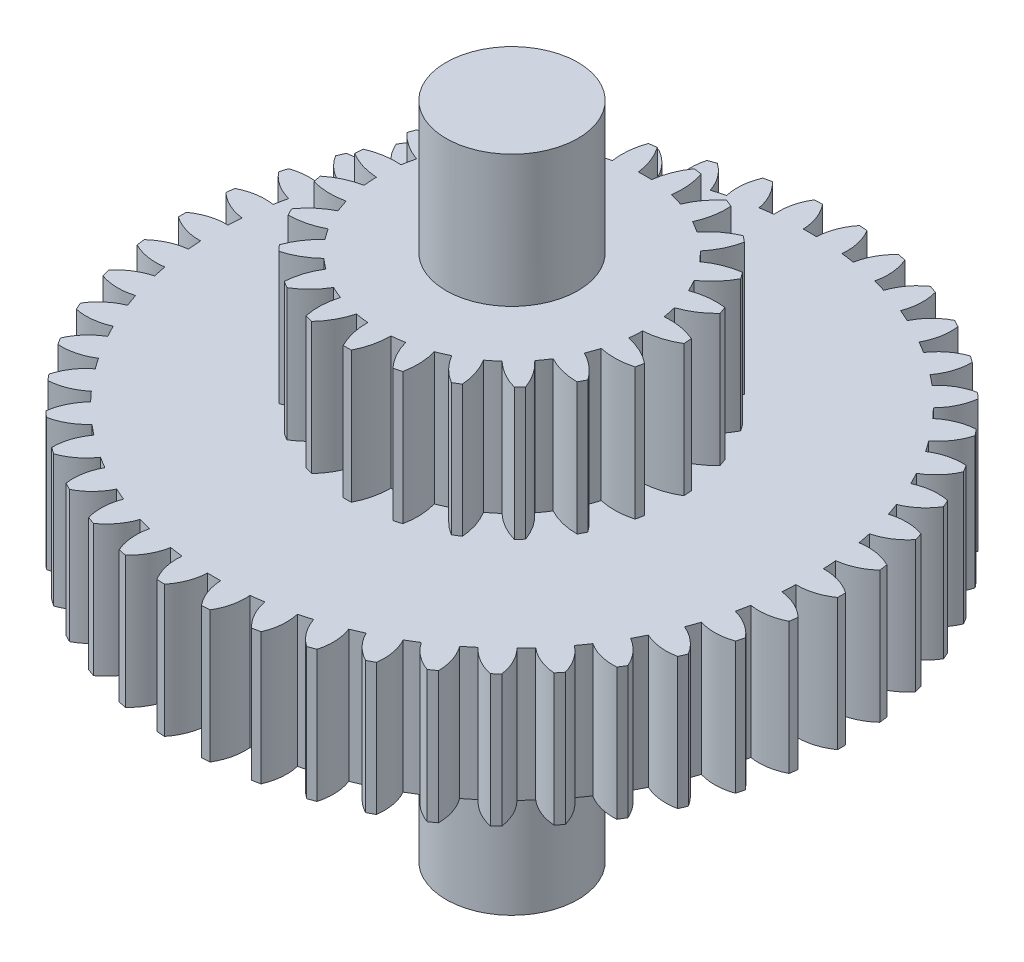
from build123d import *

# Parameters (mm, degrees)
BOSS_EXTRUDE1_DEPTH      = 1
SKETCH2_R                = 0.5
BOSS_EXTRUDE2_DEPTH      = 2
BOSS_EXTRUDE2_DEPTH_BACK = 3
BOSS_EXTRUDE3_DEPTH      = 1
SCALE1_SCALE             = 2
CUT_EXTRUDE1_DEPTH       = 2.5


with BuildPart() as part:
    # Sketch1 → Boss-Extrude1 (new body)
    with BuildSketch(Plane(origin=(0, 0, 0), x_dir=(1, 0, 0), z_dir=(0, 1, 0))):
        with BuildLine():
            ThreePointArc((-1.122849348, 2.23365381), (-1.150162594, 2.219713046), (-1.17730279, 2.20543831))
            ThreePointArc((-1.17730279, 2.20543831), (-1.174225974, 2.07727607), (-1.131251341, 1.956494417))
            ThreePointArc((-1.131251341, 1.956494417), (-1.174259727, 1.930987854), (-1.216693282, 1.904536022))
            ThreePointArc((-1.216693282, 1.904536022), (-1.3041624, 1.998259979), (-1.416540223, 2.059954804))
            ThreePointArc((-1.416540223, 2.059954804), (-1.441700805, 2.042424733), (-1.466644473, 2.024587363))
            ThreePointArc((-1.466644473, 2.024587363), (-1.446144892, 1.898037792), (-1.387124094, 1.784232818))
            ThreePointArc((-1.387124094, 1.784232818), (-1.426258754, 1.753107517), (-1.464695223, 1.721124023))
            ThreePointArc((-1.464695223, 1.721124023), (-1.564111726, 1.802064654), (-1.683843634, 1.847882739))
            ThreePointArc((-1.683843634, 1.847882739), (-1.706382858, 1.827089911), (-1.728665344, 1.806022184))
            ThreePointArc((-1.728665344, 1.806022184), (-1.691124866, 1.683442662), (-1.617157349, 1.578734337))
            ThreePointArc((-1.617157349, 1.578734337), (-1.651689279, 1.542570104), (-1.685412664, 1.505650741))
            ThreePointArc((-1.685412664, 1.505650741), (-1.79492461, 1.572300274), (-1.919780224, 1.601388114))
            ThreePointArc((-1.919780224, 1.601388114), (-1.939278227, 1.577719861), (-1.958484451, 1.553814228))
            ThreePointArc((-1.958484451, 1.553814228), (-1.904602384, 1.43748818), (-1.817066023, 1.343827023))
            ThreePointArc((-1.817066023, 1.343827023), (-1.846351958, 1.303297528), (-1.874734055, 1.262130034))
            ThreePointArc((-1.874734055, 1.262130034), (-1.992301445, 1.313246914), (-2.119954941, 1.325062658))
            ThreePointArc((-2.119954941, 1.325062658), (-2.136048511, 1.298959875), (-2.151820698, 1.272661654))
            ThreePointArc((-2.151820698, 1.272661654), (-2.082600763, 1.164756013), (-1.983126195, 1.083886754))
            ThreePointArc((-1.983126195, 1.083886754), (-2.006620594, 1.039746985), (-2.029132698, 0.995098232))
            ThreePointArc((-2.029132698, 0.995098232), (-2.152565474, 1.02973025), (-2.280638908, 1.024053793))
            ThreePointArc((-2.280638908, 1.024053793), (-2.293028254, 0.996002725), (-2.305072596, 0.967801801))
            ThreePointArc((-2.305072596, 0.967801801), (-2.22180423, 0.870326645), (-2.112244478, 0.803755726))
            ThreePointArc((-2.112244478, 0.803755726), (-2.129509684, 0.756827924), (-2.145732439, 0.709529634))
            ThreePointArc((-2.145732439, 0.709529634), (-2.272731281, 0.727031659), (-2.398838888, 0.703968742))
            ThreePointArc((-2.398838888, 0.703968742), (-2.407293218, 0.674491928), (-2.415385354, 0.644913631))
            ThreePointArc((-2.415385354, 0.644913631), (-2.319619689, 0.559684739), (-2.202015642, 0.508652249))
            ThreePointArc((-2.202015642, 0.508652249), (-2.212730038, 0.459810589), (-2.222361244, 0.41074384))
            ThreePointArc((-2.222361244, 0.41074384), (-2.350560404, 0.410789844), (-2.472353038, 0.370770087))
            ThreePointArc((-2.472353038, 0.370770087), (-2.476714865, 0.340416623), (-2.480704053, 0.310011941))
            ThreePointArc((-2.480704053, 0.310011941), (-2.374225021, 0.238616965), (-2.250767422, 0.204073543))
            ThreePointArc((-2.250767422, 0.204073543), (-2.254731418, 0.154227854), (-2.257591664, 0.104306666))
            ThreePointArc((-2.257591664, 0.104306666), (-2.384603034, 0.086895792), (-2.499811928, 0.030664685))
            ThreePointArc((-2.499811928, 0.030664685), (-2.5, 0), (-2.499811928, -0.030664685))
            ThreePointArc((-2.499811928, -0.030664685), (-2.384603034, -0.086895792), (-2.257591664, -0.104306666))
            ThreePointArc((-2.257591664, -0.104306666), (-2.254731418, -0.154227854), (-2.250767422, -0.204073543))
            ThreePointArc((-2.250767422, -0.204073543), (-2.374225021, -0.238616965), (-2.480704053, -0.310011941))
            ThreePointArc((-2.480704053, -0.310011941), (-2.476714865, -0.340416623), (-2.472353038, -0.370770087))
            ThreePointArc((-2.472353038, -0.370770087), (-2.350560404, -0.410789844), (-2.222361244, -0.41074384))
            ThreePointArc((-2.222361244, -0.41074384), (-2.212730038, -0.459810589), (-2.202015642, -0.508652249))
            ThreePointArc((-2.202015642, -0.508652249), (-2.319619689, -0.559684739), (-2.415385354, -0.644913631))
            ThreePointArc((-2.415385354, -0.644913631), (-2.407293218, -0.674491928), (-2.398838888, -0.703968742))
            ThreePointArc((-2.398838888, -0.703968742), (-2.272731281, -0.727031659), (-2.145732439, -0.709529634))
            ThreePointArc((-2.145732439, -0.709529634), (-2.129509684, -0.756827924), (-2.112244478, -0.803755726))
            ThreePointArc((-2.112244478, -0.803755726), (-2.22180423, -0.870326645), (-2.305072596, -0.967801801))
            ThreePointArc((-2.305072596, -0.967801801), (-2.293028254, -0.996002725), (-2.280638908, -1.024053793))
            ThreePointArc((-2.280638908, -1.024053793), (-2.152565474, -1.02973025), (-2.029132698, -0.995098232))
            ThreePointArc((-2.029132698, -0.995098232), (-2.006620594, -1.039746985), (-1.983126195, -1.083886754))
            ThreePointArc((-1.983126195, -1.083886754), (-2.082600763, -1.164756013), (-2.151820698, -1.272661654))
            ThreePointArc((-2.151820698, -1.272661654), (-2.136048511, -1.298959875), (-2.119954941, -1.325062658))
            ThreePointArc((-2.119954941, -1.325062658), (-1.992301445, -1.313246914), (-1.874734055, -1.262130034))
            ThreePointArc((-1.874734055, -1.262130034), (-1.846351958, -1.303297528), (-1.817066023, -1.343827023))
            ThreePointArc((-1.817066023, -1.343827023), (-1.904602384, -1.43748818), (-1.958484451, -1.553814228))
            ThreePointArc((-1.958484451, -1.553814228), (-1.939278227, -1.577719861), (-1.919780224, -1.601388114))
            ThreePointArc((-1.919780224, -1.601388114), (-1.79492461, -1.572300274), (-1.685412664, -1.505650741))
            ThreePointArc((-1.685412664, -1.505650741), (-1.651689279, -1.542570104), (-1.617157349, -1.578734337))
            ThreePointArc((-1.617157349, -1.578734337), (-1.691124866, -1.683442662), (-1.728665344, -1.806022184))
            ThreePointArc((-1.728665344, -1.806022184), (-1.706382858, -1.827089911), (-1.683843634, -1.847882739))
            ThreePointArc((-1.683843634, -1.847882739), (-1.564111726, -1.802064654), (-1.464695223, -1.721124023))
            ThreePointArc((-1.464695223, -1.721124023), (-1.426258754, -1.753107517), (-1.387124094, -1.784232818))
            ThreePointArc((-1.387124094, -1.784232818), (-1.446144892, -1.898037792), (-1.466644473, -2.024587363))
            ThreePointArc((-1.466644473, -2.024587363), (-1.441700805, -2.042424733), (-1.416540223, -2.059954804))
            ThreePointArc((-1.416540223, -2.059954804), (-1.3041624, -1.998259979), (-1.216693282, -1.904536022))
            ThreePointArc((-1.216693282, -1.904536022), (-1.174259727, -1.930987854), (-1.131251341, -1.956494417))
            ThreePointArc((-1.131251341, -1.956494417), (-1.174225974, -2.07727607), (-1.17730279, -2.20543831))
            ThreePointArc((-1.17730279, -2.20543831), (-1.150162594, -2.219713046), (-1.122849348, -2.23365381))
            ThreePointArc((-1.122849348, -2.23365381), (-1.019918995, -2.157231501), (-0.946026647, -2.052470118))
            ThreePointArc((-0.946026647, -2.052470118), (-0.900386463, -2.072897541), (-0.854305516, -2.092310227))
            ThreePointArc((-0.854305516, -2.092310227), (-0.880433448, -2.217818624), (-0.866030184, -2.345206115))
            ThreePointArc((-0.866030184, -2.345206115), (-0.83719903, -2.355652305), (-0.808241914, -2.365744071))
            ThreePointArc((-0.808241914, -2.365744071), (-0.71667643, -2.276017883), (-0.657737325, -2.162170579))
            ThreePointArc((-0.657737325, -2.162170579), (-0.609740703, -2.176193069), (-0.561445596, -2.189150256))
            ThreePointArc((-0.561445596, -2.189150256), (-0.570240113, -2.317047414), (-0.538625074, -2.441287167))
            ThreePointArc((-0.538625074, -2.441287167), (-0.508640033, -2.447710219), (-0.478578463, -2.453764996))
            ThreePointArc((-0.478578463, -2.453764996), (-0.400083539, -2.352406357), (-0.357195602, -2.231593893))
            ThreePointArc((-0.357195602, -2.231593893), (-0.307736627, -2.238950238), (-0.258127007, -2.245210558))
            ThreePointArc((-0.258127007, -2.245210558), (-0.249424284, -2.373113995), (-0.201186398, -2.491891658))
            ThreePointArc((-0.201186398, -2.491891658), (-0.170606033, -2.494171923), (-0.14, -2.496076922))
            ThreePointArc((-0.14, -2.496076922), (-0.076037848, -2.384973952), (-0.05, -2.259446835))
            ThreePointArc((-0.05, -2.259446835), (0, -2.26), (0.05, -2.259446835))
            ThreePointArc((0.05, -2.259446835), (0.076037848, -2.384973952), (0.14, -2.496076922))
            ThreePointArc((0.14, -2.496076922), (0.170606033, -2.494171923), (0.201186398, -2.491891658))
            ThreePointArc((0.201186398, -2.491891658), (0.249424284, -2.373113995), (0.258127007, -2.245210558))
            ThreePointArc((0.258127007, -2.245210558), (0.307736627, -2.238950238), (0.357195602, -2.231593893))
            ThreePointArc((0.357195602, -2.231593893), (0.400083539, -2.352406357), (0.478578463, -2.453764996))
            ThreePointArc((0.478578463, -2.453764996), (0.508640033, -2.447710219), (0.538625074, -2.441287167))
            ThreePointArc((0.538625074, -2.441287167), (0.570240113, -2.317047414), (0.561445596, -2.189150256))
            ThreePointArc((0.561445596, -2.189150256), (0.609740703, -2.176193069), (0.657737325, -2.162170579))
            ThreePointArc((0.657737325, -2.162170579), (0.71667643, -2.276017883), (0.808241914, -2.365744071))
            ThreePointArc((0.808241914, -2.365744071), (0.83719903, -2.355652305), (0.866030184, -2.345206115))
            ThreePointArc((0.866030184, -2.345206115), (0.880433448, -2.217818624), (0.854305516, -2.092310227))
            ThreePointArc((0.854305516, -2.092310227), (0.900386463, -2.072897541), (0.946026647, -2.052470118))
            ThreePointArc((0.946026647, -2.052470118), (1.019918995, -2.157231501), (1.122849348, -2.23365381))
            ThreePointArc((1.122849348, -2.23365381), (1.150162594, -2.219713046), (1.17730279, -2.20543831))
            ThreePointArc((1.17730279, -2.20543831), (1.174225974, -2.07727607), (1.131251341, -1.956494417))
            ThreePointArc((1.131251341, -1.956494417), (1.174259727, -1.930987854), (1.216693282, -1.904536022))
            ThreePointArc((1.216693282, -1.904536022), (1.3041624, -1.998259979), (1.416540223, -2.059954804))
            ThreePointArc((1.416540223, -2.059954804), (1.441700805, -2.042424733), (1.466644473, -2.024587363))
            ThreePointArc((1.466644473, -2.024587363), (1.446144892, -1.898037792), (1.387124094, -1.784232818))
            ThreePointArc((1.387124094, -1.784232818), (1.426258754, -1.753107517), (1.464695223, -1.721124023))
            ThreePointArc((1.464695223, -1.721124023), (1.564111726, -1.802064654), (1.683843634, -1.847882739))
            ThreePointArc((1.683843634, -1.847882739), (1.706382858, -1.827089911), (1.728665344, -1.806022184))
            ThreePointArc((1.728665344, -1.806022184), (1.691124866, -1.683442662), (1.617157349, -1.578734337))
            ThreePointArc((1.617157349, -1.578734337), (1.651689279, -1.542570104), (1.685412664, -1.505650741))
            ThreePointArc((1.685412664, -1.505650741), (1.79492461, -1.572300274), (1.919780224, -1.601388114))
            ThreePointArc((1.919780224, -1.601388114), (1.939278227, -1.577719861), (1.958484451, -1.553814228))
            ThreePointArc((1.958484451, -1.553814228), (1.904602384, -1.43748818), (1.817066023, -1.343827023))
            ThreePointArc((1.817066023, -1.343827023), (1.846351958, -1.303297528), (1.874734055, -1.262130034))
            ThreePointArc((1.874734055, -1.262130034), (1.992301445, -1.313246914), (2.119954941, -1.325062658))
            ThreePointArc((2.119954941, -1.325062658), (2.136048511, -1.298959875), (2.151820698, -1.272661654))
            ThreePointArc((2.151820698, -1.272661654), (2.082600763, -1.164756013), (1.983126195, -1.083886754))
            ThreePointArc((1.983126195, -1.083886754), (2.006620594, -1.039746985), (2.029132698, -0.995098232))
            ThreePointArc((2.029132698, -0.995098232), (2.152565474, -1.02973025), (2.280638908, -1.024053793))
            ThreePointArc((2.280638908, -1.024053793), (2.293028254, -0.996002725), (2.305072596, -0.967801801))
            ThreePointArc((2.305072596, -0.967801801), (2.22180423, -0.870326645), (2.112244478, -0.803755726))
            ThreePointArc((2.112244478, -0.803755726), (2.129509684, -0.756827924), (2.145732439, -0.709529634))
            ThreePointArc((2.145732439, -0.709529634), (2.272731281, -0.727031659), (2.398838888, -0.703968742))
            ThreePointArc((2.398838888, -0.703968742), (2.407293218, -0.674491928), (2.415385354, -0.644913631))
            ThreePointArc((2.415385354, -0.644913631), (2.319619689, -0.559684739), (2.202015642, -0.508652249))
            ThreePointArc((2.202015642, -0.508652249), (2.212730038, -0.459810589), (2.222361244, -0.41074384))
            ThreePointArc((2.222361244, -0.41074384), (2.350560404, -0.410789844), (2.472353038, -0.370770087))
            ThreePointArc((2.472353038, -0.370770087), (2.476714865, -0.340416623), (2.480704053, -0.310011941))
            ThreePointArc((2.480704053, -0.310011941), (2.374225021, -0.238616965), (2.250767422, -0.204073543))
            ThreePointArc((2.250767422, -0.204073543), (2.254731418, -0.154227854), (2.257591664, -0.104306666))
            ThreePointArc((2.257591664, -0.104306666), (2.384603034, -0.086895792), (2.499811928, -0.030664685))
            ThreePointArc((2.499811928, -0.030664685), (2.5, 0), (2.499811928, 0.030664685))
            ThreePointArc((2.499811928, 0.030664685), (2.384603034, 0.086895792), (2.257591664, 0.104306666))
            ThreePointArc((2.257591664, 0.104306666), (2.254731418, 0.154227854), (2.250767422, 0.204073543))
            ThreePointArc((2.250767422, 0.204073543), (2.374225021, 0.238616965), (2.480704053, 0.310011941))
            ThreePointArc((2.480704053, 0.310011941), (2.476714865, 0.340416623), (2.472353038, 0.370770087))
            ThreePointArc((2.472353038, 0.370770087), (2.350560404, 0.410789844), (2.222361244, 0.41074384))
            ThreePointArc((2.222361244, 0.41074384), (2.212730038, 0.459810589), (2.202015642, 0.508652249))
            ThreePointArc((2.202015642, 0.508652249), (2.319619689, 0.559684739), (2.415385354, 0.644913631))
            ThreePointArc((2.415385354, 0.644913631), (2.407293218, 0.674491928), (2.398838888, 0.703968742))
            ThreePointArc((2.398838888, 0.703968742), (2.272731281, 0.727031659), (2.145732439, 0.709529634))
            ThreePointArc((2.145732439, 0.709529634), (2.129509684, 0.756827924), (2.112244478, 0.803755726))
            ThreePointArc((2.112244478, 0.803755726), (2.22180423, 0.870326645), (2.305072596, 0.967801801))
            ThreePointArc((2.305072596, 0.967801801), (2.293028254, 0.996002725), (2.280638908, 1.024053793))
            ThreePointArc((2.280638908, 1.024053793), (2.152565474, 1.02973025), (2.029132698, 0.995098232))
            ThreePointArc((2.029132698, 0.995098232), (2.006620594, 1.039746985), (1.983126195, 1.083886754))
            ThreePointArc((1.983126195, 1.083886754), (2.082600763, 1.164756013), (2.151820698, 1.272661654))
            ThreePointArc((2.151820698, 1.272661654), (2.136048511, 1.298959875), (2.119954941, 1.325062658))
            ThreePointArc((2.119954941, 1.325062658), (1.992301445, 1.313246914), (1.874734055, 1.262130034))
            ThreePointArc((1.874734055, 1.262130034), (1.846351958, 1.303297528), (1.817066023, 1.343827023))
            ThreePointArc((1.817066023, 1.343827023), (1.904602384, 1.43748818), (1.958484451, 1.553814228))
            ThreePointArc((1.958484451, 1.553814228), (1.939278227, 1.577719861), (1.919780224, 1.601388114))
            ThreePointArc((1.919780224, 1.601388114), (1.79492461, 1.572300274), (1.685412664, 1.505650741))
            ThreePointArc((1.685412664, 1.505650741), (1.651689279, 1.542570104), (1.617157349, 1.578734337))
            ThreePointArc((1.617157349, 1.578734337), (1.691124866, 1.683442662), (1.728665344, 1.806022184))
            ThreePointArc((1.728665344, 1.806022184), (1.706382858, 1.827089911), (1.683843634, 1.847882739))
            ThreePointArc((1.683843634, 1.847882739), (1.564111726, 1.802064654), (1.464695223, 1.721124023))
            ThreePointArc((1.464695223, 1.721124023), (1.426258754, 1.753107517), (1.387124094, 1.784232818))
            ThreePointArc((1.387124094, 1.784232818), (1.446144892, 1.898037792), (1.466644473, 2.024587363))
            ThreePointArc((1.466644473, 2.024587363), (1.441700805, 2.042424733), (1.416540223, 2.059954804))
            ThreePointArc((1.416540223, 2.059954804), (1.3041624, 1.998259979), (1.216693282, 1.904536022))
            ThreePointArc((1.216693282, 1.904536022), (1.174259727, 1.930987854), (1.131251341, 1.956494417))
            ThreePointArc((1.131251341, 1.956494417), (1.174225974, 2.07727607), (1.17730279, 2.20543831))
            ThreePointArc((1.17730279, 2.20543831), (1.150162594, 2.219713046), (1.122849348, 2.23365381))
            ThreePointArc((1.122849348, 2.23365381), (1.019918995, 2.157231501), (0.946026647, 2.052470118))
            ThreePointArc((0.946026647, 2.052470118), (0.900386463, 2.072897541), (0.854305516, 2.092310227))
            ThreePointArc((0.854305516, 2.092310227), (0.880433448, 2.217818624), (0.866030184, 2.345206115))
            ThreePointArc((0.866030184, 2.345206115), (0.83719903, 2.355652305), (0.808241914, 2.365744071))
            ThreePointArc((0.808241914, 2.365744071), (0.71667643, 2.276017883), (0.657737325, 2.162170579))
            ThreePointArc((0.657737325, 2.162170579), (0.609740703, 2.176193069), (0.561445596, 2.189150256))
            ThreePointArc((0.561445596, 2.189150256), (0.570240113, 2.317047414), (0.538625074, 2.441287167))
            ThreePointArc((0.538625074, 2.441287167), (0.508640033, 2.447710219), (0.478578463, 2.453764996))
            ThreePointArc((0.478578463, 2.453764996), (0.400083539, 2.352406357), (0.357195602, 2.231593893))
            ThreePointArc((0.357195602, 2.231593893), (0.307736627, 2.238950238), (0.258127007, 2.245210558))
            ThreePointArc((0.258127007, 2.245210558), (0.249424284, 2.373113995), (0.201186398, 2.491891658))
            ThreePointArc((0.201186398, 2.491891658), (0.170606033, 2.494171923), (0.14, 2.496076922))
            ThreePointArc((0.14, 2.496076922), (0.076037848, 2.384973952), (0.05, 2.259446835))
            ThreePointArc((0.05, 2.259446835), (0, 2.26), (-0.05, 2.259446835))
            ThreePointArc((-0.05, 2.259446835), (-0.076037848, 2.384973952), (-0.14, 2.496076922))
            ThreePointArc((-0.14, 2.496076922), (-0.170606033, 2.494171923), (-0.201186398, 2.491891658))
            ThreePointArc((-0.201186398, 2.491891658), (-0.249424284, 2.373113995), (-0.258127007, 2.245210558))
            ThreePointArc((-0.258127007, 2.245210558), (-0.307736627, 2.238950238), (-0.357195602, 2.231593893))
            ThreePointArc((-0.357195602, 2.231593893), (-0.400083539, 2.352406357), (-0.478578463, 2.453764996))
            ThreePointArc((-0.478578463, 2.453764996), (-0.508640033, 2.447710219), (-0.538625074, 2.441287167))
            ThreePointArc((-0.538625074, 2.441287167), (-0.570240113, 2.317047414), (-0.561445596, 2.189150256))
            ThreePointArc((-0.561445596, 2.189150256), (-0.609740703, 2.176193069), (-0.657737325, 2.162170579))
            ThreePointArc((-0.657737325, 2.162170579), (-0.71667643, 2.276017883), (-0.808241914, 2.365744071))
            ThreePointArc((-0.808241914, 2.365744071), (-0.83719903, 2.355652305), (-0.866030184, 2.345206115))
            ThreePointArc((-0.866030184, 2.345206115), (-0.880433448, 2.217818624), (-0.854305516, 2.092310227))
            ThreePointArc((-0.854305516, 2.092310227), (-0.900386463, 2.072897541), (-0.946026647, 2.052470118))
            ThreePointArc((-0.946026647, 2.052470118), (-1.019918995, 2.157231501), (-1.122849348, 2.23365381))
        make_face()
    extrude(amount=BOSS_EXTRUDE1_DEPTH)

    # Sketch2 → Boss-Extrude2 (add, two sides)
    with BuildSketch(Plane.XZ) as boss_extrude2_sk:
        Circle(SKETCH2_R)
    extrude(amount=BOSS_EXTRUDE2_DEPTH)
    extrude(boss_extrude2_sk.sketch, amount=-BOSS_EXTRUDE2_DEPTH_BACK)

    # Sketch3 → Boss-Extrude3 (add)
    with BuildSketch(Plane(origin=(0, 1, 0), x_dir=(1, 0, 0), z_dir=(0, 1, 0))):
        with BuildLine():
            ThreePointArc((-0.765012261, 0.988562715), (-0.78885993, 0.969639113), (-0.812239679, 0.95014036))
            ThreePointArc((-0.812239679, 0.95014036), (-0.771519926, 0.830895064), (-0.703111612, 0.725075211))
            ThreePointArc((-0.703111612, 0.725075211), (-0.738144324, 0.689378675), (-0.771366926, 0.651991614))
            ThreePointArc((-0.771366926, 0.651991614), (-0.881608438, 0.71301905), (-1.003354559, 0.74550629))
            ThreePointArc((-1.003354559, 0.74550629), (-1.021212366, 0.720850403), (-1.03846443, 0.695766935))
            ThreePointArc((-1.03846443, 0.695766935), (-0.96708268, 0.591929637), (-0.872661277, 0.508490212))
            ThreePointArc((-0.872661277, 0.508490212), (-0.896764071, 0.464665688), (-0.918667781, 0.41970169))
            ThreePointArc((-0.918667781, 0.41970169), (-1.041286243, 0.44872326), (-1.16728264, 0.447159074))
            ThreePointArc((-1.16728264, 0.447159074), (-1.177826153, 0.418599515), (-1.187671024, 0.38979166))
            ThreePointArc((-1.187671024, 0.38979166), (-1.090921335, 0.309063496), (-0.977489647, 0.254192821))
            ThreePointArc((-0.977489647, 0.254192821), (-0.988874929, 0.205490573), (-0.997835248, 0.156284412))
            ThreePointArc((-0.997835248, 0.156284412), (-1.123736611, 0.151147718), (-1.244638708, 0.115648115))
            ThreePointArc((-1.244638708, 0.115648115), (-1.247085961, 0.085303017), (-1.248793492, 0.05490732))
            ThreePointArc((-1.248793492, 0.05490732), (-1.133851346, 0.003275529), (-1.009822082, -0.018956889))
            ThreePointArc((-1.009822082, -0.018956889), (-1.007645457, -0.068924837), (-1.00299784, -0.118723766))
            ThreePointArc((-1.00299784, -0.118723766), (-1.122844575, -0.157637759), (-1.229685616, -0.224439935))
            ThreePointArc((-1.229685616, -0.224439935), (-1.22385511, -0.254320016), (-1.21729866, -0.284049244))
            ThreePointArc((-1.21729866, -0.284049244), (-1.092688789, -0.302755369), (-0.967260632, -0.290700653))
            ThreePointArc((-0.967260632, -0.290700653), (-0.951683531, -0.338228408), (-0.933772671, -0.384926745))
            ThreePointArc((-0.933772671, -0.384926745), (-1.038676294, -0.454731964), (-1.123532368, -0.547882303))
            ThreePointArc((-1.123532368, -0.547882303), (-1.109856523, -0.575081297), (-1.095522354, -0.601939176))
            ThreePointArc((-1.095522354, -0.601939176), (-0.970486504, -0.586332286), (-0.852961886, -0.54088448))
            ThreePointArc((-0.852961886, -0.54088448), (-0.825139592, -0.582447125), (-0.795293854, -0.622581469))
            ThreePointArc((-0.795293854, -0.622581469), (-0.877474144, -0.71810078), (-0.934051864, -0.830690746))
            ThreePointArc((-0.934051864, -0.830690746), (-0.913544955, -0.853191429), (-0.892496167, -0.875186032))
            ThreePointArc((-0.892496167, -0.875186032), (-0.776307675, -0.826423619), (-0.67540286, -0.750953379))
            ThreePointArc((-0.67540286, -0.750953379), (-0.637398824, -0.783468404), (-0.597831731, -0.814062173))
            ThreePointArc((-0.597831731, -0.814062173), (-0.651193751, -0.928211346), (-0.675297006, -1.051890657))
            ThreePointArc((-0.675297006, -1.051890657), (-0.649479938, -1.068024256), (-0.623277623, -1.083524344))
            ThreePointArc((-0.623277623, -1.083524344), (-0.524553656, -1.005222894), (-0.447752293, -0.905327501))
            ThreePointArc((-0.447752293, -0.905327501), (-0.402385101, -0.926383415), (-0.356031163, -0.94516761))
            ThreePointArc((-0.356031163, -0.94516761), (-0.376617296, -1.069480723), (-0.366458458, -1.19507665))
            ThreePointArc((-0.366458458, -1.19507665), (-0.337245964, -1.203646609), (-0.307833428, -1.211502613))
            ThreePointArc((-0.307833428, -1.211502613), (-0.233895893, -1.109469385), (-0.186893986, -0.992557624))
            ThreePointArc((-0.186893986, -0.992557624), (-0.137528316, -1.000592805), (-0.087825392, -1.006174289))
            ThreePointArc((-0.087825392, -1.006174289), (-0.074108859, -1.131431607), (-0.030441363, -1.249629274))
            ThreePointArc((-0.030441363, -1.249629274), (0, -1.25), (0.030441363, -1.249629274))
            ThreePointArc((0.030441363, -1.249629274), (0.074108859, -1.131431607), (0.087825392, -1.006174289))
            ThreePointArc((0.087825392, -1.006174289), (0.137528316, -1.000592805), (0.186893986, -0.992557624))
            ThreePointArc((0.186893986, -0.992557624), (0.233895893, -1.109469385), (0.307833428, -1.211502613))
            ThreePointArc((0.307833428, -1.211502613), (0.337245964, -1.203646609), (0.366458458, -1.19507665))
            ThreePointArc((0.366458458, -1.19507665), (0.376617296, -1.069480723), (0.356031163, -0.94516761))
            ThreePointArc((0.356031163, -0.94516761), (0.402385101, -0.926383415), (0.447752293, -0.905327501))
            ThreePointArc((0.447752293, -0.905327501), (0.524553656, -1.005222894), (0.623277623, -1.083524344))
            ThreePointArc((0.623277623, -1.083524344), (0.649479938, -1.068024256), (0.675297006, -1.051890657))
            ThreePointArc((0.675297006, -1.051890657), (0.651193751, -0.928211346), (0.597831731, -0.814062173))
            ThreePointArc((0.597831731, -0.814062173), (0.637398824, -0.783468404), (0.67540286, -0.750953379))
            ThreePointArc((0.67540286, -0.750953379), (0.776307675, -0.826423619), (0.892496167, -0.875186032))
            ThreePointArc((0.892496167, -0.875186032), (0.913544955, -0.853191429), (0.934051864, -0.830690746))
            ThreePointArc((0.934051864, -0.830690746), (0.877474144, -0.71810078), (0.795293854, -0.622581469))
            ThreePointArc((0.795293854, -0.622581469), (0.825139592, -0.582447125), (0.852961886, -0.54088448))
            ThreePointArc((0.852961886, -0.54088448), (0.970486504, -0.586332286), (1.095522354, -0.601939176))
            ThreePointArc((1.095522354, -0.601939176), (1.109856523, -0.575081297), (1.123532368, -0.547882303))
            ThreePointArc((1.123532368, -0.547882303), (1.038676294, -0.454731964), (0.933772671, -0.384926745))
            ThreePointArc((0.933772671, -0.384926745), (0.951683531, -0.338228408), (0.967260632, -0.290700653))
            ThreePointArc((0.967260632, -0.290700653), (1.092688789, -0.302755369), (1.21729866, -0.284049244))
            ThreePointArc((1.21729866, -0.284049244), (1.22385511, -0.254320016), (1.229685616, -0.224439935))
            ThreePointArc((1.229685616, -0.224439935), (1.122844575, -0.157637759), (1.00299784, -0.118723766))
            ThreePointArc((1.00299784, -0.118723766), (1.007645457, -0.068924837), (1.009822082, -0.018956889))
            ThreePointArc((1.009822082, -0.018956889), (1.133851346, 0.003275529), (1.248793492, 0.05490732))
            ThreePointArc((1.248793492, 0.05490732), (1.247085961, 0.085303017), (1.244638708, 0.115648115))
            ThreePointArc((1.244638708, 0.115648115), (1.123736611, 0.151147718), (0.997835248, 0.156284412))
            ThreePointArc((0.997835248, 0.156284412), (0.988874929, 0.205490573), (0.977489647, 0.254192821))
            ThreePointArc((0.977489647, 0.254192821), (1.090921335, 0.309063496), (1.187671024, 0.38979166))
            ThreePointArc((1.187671024, 0.38979166), (1.177826153, 0.418599515), (1.16728264, 0.447159074))
            ThreePointArc((1.16728264, 0.447159074), (1.041286243, 0.44872326), (0.918667781, 0.41970169))
            ThreePointArc((0.918667781, 0.41970169), (0.896764071, 0.464665688), (0.872661277, 0.508490212))
            ThreePointArc((0.872661277, 0.508490212), (0.96708268, 0.591929637), (1.03846443, 0.695766935))
            ThreePointArc((1.03846443, 0.695766935), (1.021212366, 0.720850403), (1.003354559, 0.74550629))
            ThreePointArc((1.003354559, 0.74550629), (0.881608438, 0.71301905), (0.771366926, 0.651991614))
            ThreePointArc((0.771366926, 0.651991614), (0.738144324, 0.689378675), (0.703111612, 0.725075211))
            ThreePointArc((0.703111612, 0.725075211), (0.771519926, 0.830895064), (0.812239679, 0.95014036))
            ThreePointArc((0.812239679, 0.95014036), (0.78885993, 0.969639113), (0.765012261, 0.988562715))
            ThreePointArc((0.765012261, 0.988562715), (0.656545768, 0.92443348), (0.566857316, 0.835926303))
            ThreePointArc((0.566857316, 0.835926303), (0.52477979, 0.862963599), (0.481415375, 0.887884698))
            ThreePointArc((0.481415375, 0.887884698), (0.518737068, 1.008236806), (0.525774827, 1.134046221))
            ThreePointArc((0.525774827, 1.134046221), (0.498001362, 1.146514127), (0.469932502, 1.158301966))
            ThreePointArc((0.469932502, 1.158301966), (0.382790102, 1.067286907), (0.320306492, 0.957864161))
            ThreePointArc((0.320306492, 0.957864161), (0.272494739, 0.97254646), (0.224014763, 0.984843838))
            ThreePointArc((0.224014763, 0.984843838), (0.227481856, 1.110802237), (0.200315662, 1.233845061))
            ThreePointArc((0.200315662, 1.233845061), (0.170208311, 1.238357433), (0.14, 1.242135258))
            ThreePointArc((0.14, 1.242135258), (0.080644645, 1.130984547), (0.05, 1.008761617))
            ThreePointArc((0.05, 1.008761617), (0, 1.01), (-0.05, 1.008761617))
            ThreePointArc((-0.05, 1.008761617), (-0.080644645, 1.130984547), (-0.14, 1.242135258))
            ThreePointArc((-0.14, 1.242135258), (-0.170208311, 1.238357433), (-0.200315662, 1.233845061))
            ThreePointArc((-0.200315662, 1.233845061), (-0.227481856, 1.110802237), (-0.224014763, 0.984843838))
            ThreePointArc((-0.224014763, 0.984843838), (-0.272494739, 0.97254646), (-0.320306492, 0.957864161))
            ThreePointArc((-0.320306492, 0.957864161), (-0.382790102, 1.067286907), (-0.469932502, 1.158301966))
            ThreePointArc((-0.469932502, 1.158301966), (-0.498001362, 1.146514127), (-0.525774827, 1.134046221))
            ThreePointArc((-0.525774827, 1.134046221), (-0.518737068, 1.008236806), (-0.481415375, 0.887884698))
            ThreePointArc((-0.481415375, 0.887884698), (-0.52477979, 0.862963599), (-0.566857316, 0.835926303))
            ThreePointArc((-0.566857316, 0.835926303), (-0.656545768, 0.92443348), (-0.765012261, 0.988562715))
        make_face()
    extrude(amount=BOSS_EXTRUDE3_DEPTH)


with BuildPart() as part_1:
    # Scale1: scaled about (0, 0, 0)
    add(part.part.scale(SCALE1_SCALE))

    # Sketch4 → Cut-Extrude1 (cut)
    with BuildSketch(Plane.XZ.offset(4)):
        with BuildLine():
            Line((-0.75, 0), (-0.75, -0.661437828))
            ThreePointArc((-0.75, -0.661437828), (-1, 0), (-0.75, 0.661437828))
            Line((-0.75, 0.661437828), (-0.75, 0))
        make_face()
    extrude(amount=-CUT_EXTRUDE1_DEPTH, mode=Mode.SUBTRACT)


solid = part_1.part
